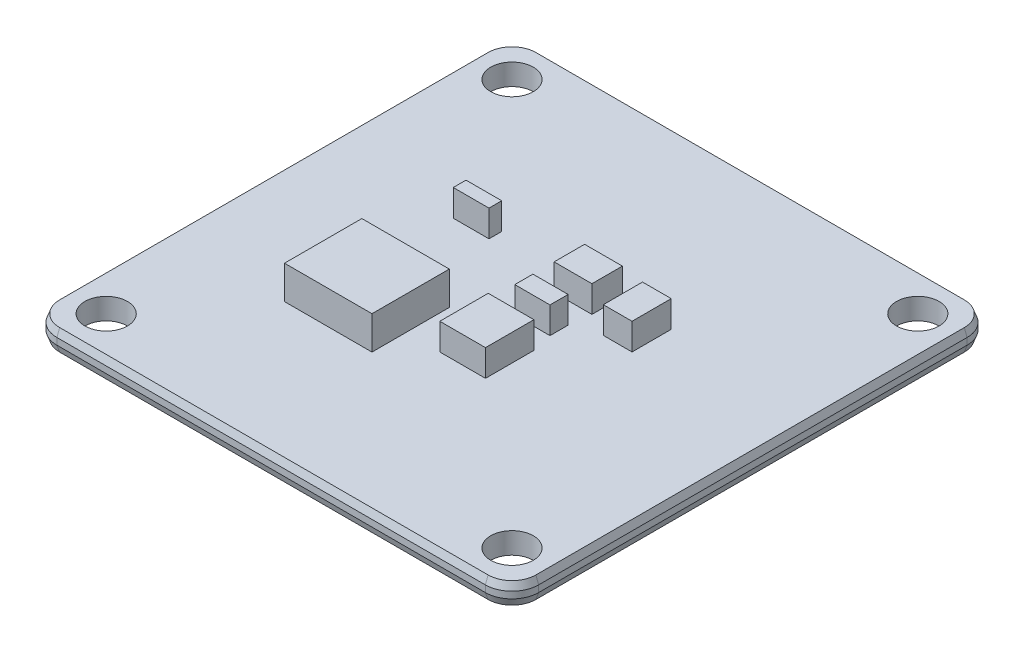
from build123d import *

# Parameters (mm, degrees)
ESQUISSE1_R        = 1.6
BOSS_EXTRU_1_DEPTH = 1.6
CHANFREIN1_SIZE    = 0.2
CHANFREIN1_SIZE2   = 0.549495484
CHANFREIN2_SIZE    = 0.2
CHANFREIN2_SIZE2   = 0.549495484
ESQUISSE4_W        = 6.573690578
ESQUISSE4_H        = 5.811523554
BOSS_EXTRU_2_DEPTH = 2.5
ESQUISSE5_W        = 2.839601435
ESQUISSE5_H        = 2.289720849
ESQUISSE5_W_2      = 2.157836197
ESQUISSE5_H_2      = 2.945915503
ESQUISSE5_W_3      = 2.645694815
ESQUISSE5_H_3      = 1.363110326
ESQUISSE5_W_4      = 3.433774122
ESQUISSE5_H_4      = 3.640175845
ESQUISSE5_W_5      = 2.683222401
ESQUISSE5_H_5      = 0.956953443
BOSS_EXTRU_3_DEPTH = 2


with BuildPart() as part:
    # Esquisse1 → Boss.-Extru.1 (new body)
    with BuildSketch(Plane(origin=(0, 0, 0), x_dir=(1, 0, 0), z_dir=(0, 1, 0))):
        with BuildLine():
            Line((16.1, -18.1), (-16.1, -18.1))
            ThreePointArc((-16.1, -18.1), (-17.514213562, -17.514213562), (-18.1, -16.1))
            Line((-18.1, -16.1), (-18.1, 16.1))
            ThreePointArc((-18.1, 16.1), (-17.514213562, 17.514213562), (-16.1, 18.1))
            Line((-16.1, 18.1), (16.1, 18.1))
            ThreePointArc((16.1, 18.1), (17.514213562, 17.514213562), (18.1, 16.1))
            Line((18.1, 16.1), (18.1, -16.1))
            ThreePointArc((18.1, -16.1), (17.514213562, -17.514213562), (16.1, -18.1))
        make_face()
        with Locations((-15.25, 15.25)):
            Circle(ESQUISSE1_R, mode=Mode.SUBTRACT)
        with Locations((15.25, 15.25)):
            Circle(ESQUISSE1_R, mode=Mode.SUBTRACT)
        with Locations((15.25, -15.25)):
            Circle(ESQUISSE1_R, mode=Mode.SUBTRACT)
        with Locations((-15.25, -15.25)):
            Circle(ESQUISSE1_R, mode=Mode.SUBTRACT)
    extrude(amount=BOSS_EXTRU_1_DEPTH)

    # Chanfrein1
    chanfrein1_edges = [part.edges().sort_by_distance(p)[0] for p in [
        (17.514213562, 1.6, -17.514213562),
        (0, 1.6, -18.1),
        (-17.514213562, 1.6, -17.514213562),
        (-18.1, 1.6, 0),
        (-17.514213562, 1.6, 17.514213562),
        (0, 1.6, 18.1),
        (17.514213562, 1.6, 17.514213562),
        (18.1, 1.6, 0),
    ]]
    chanfrein1_side = [part.faces().sort_by_distance(p)[0] for p in [
        (0, 1.6, 0),
    ]]
    chamfer(chanfrein1_edges, length=CHANFREIN1_SIZE, length2=CHANFREIN1_SIZE2, reference=chanfrein1_side[0])

    # Chanfrein2
    chanfrein2_edges = [part.edges().sort_by_distance(p)[0] for p in [
        (18.1, 0, 0),
        (17.514213562, 0, 17.514213562),
        (0, 0, 18.1),
        (-17.514213562, 0, 17.514213562),
        (-18.1, 0, 0),
        (-17.514213562, 0, -17.514213562),
        (0, 0, -18.1),
        (17.514213562, 0, -17.514213562),
    ]]
    chanfrein2_side = [part.faces().sort_by_distance(p)[0] for p in [
        (0, 0, 0),
    ]]
    chamfer(chanfrein2_edges, length=CHANFREIN2_SIZE, length2=CHANFREIN2_SIZE2, reference=chanfrein2_side[0])

    # Esquisse4 → Boss.-Extru.2 (add)
    with BuildSketch(Plane(origin=(0, 1.6, 0), x_dir=(1, 0, 0), z_dir=(0, 1, 0))):
        with Locations((-6.049700749, -4.854717359)):
            Rectangle(ESQUISSE4_W, ESQUISSE4_H)
    extrude(amount=BOSS_EXTRU_2_DEPTH)

    # Esquisse5 → Boss.-Extru.3 (add)
    with BuildSketch(Plane(origin=(0, 1.6, 0), x_dir=(1, 0, 0), z_dir=(0, 1, 0))):
        with Locations((1.628867377, 4.102355057)):
            Rectangle(ESQUISSE5_W, ESQUISSE5_H)
        with Locations((5.922641632, 3.492800834)):
            Rectangle(ESQUISSE5_W_2, ESQUISSE5_H_2)
        with Locations((1.531914066, 0.681555163)):
            Rectangle(ESQUISSE5_W_3, ESQUISSE5_H_3)
        with Locations((1.49438648, -3.384129307)):
            Rectangle(ESQUISSE5_W_4, ESQUISSE5_H_4)
        with Locations((-7.080666928, 4.487281863)):
            Rectangle(ESQUISSE5_W_5, ESQUISSE5_H_5)
    extrude(amount=BOSS_EXTRU_3_DEPTH)


solid = part.part
